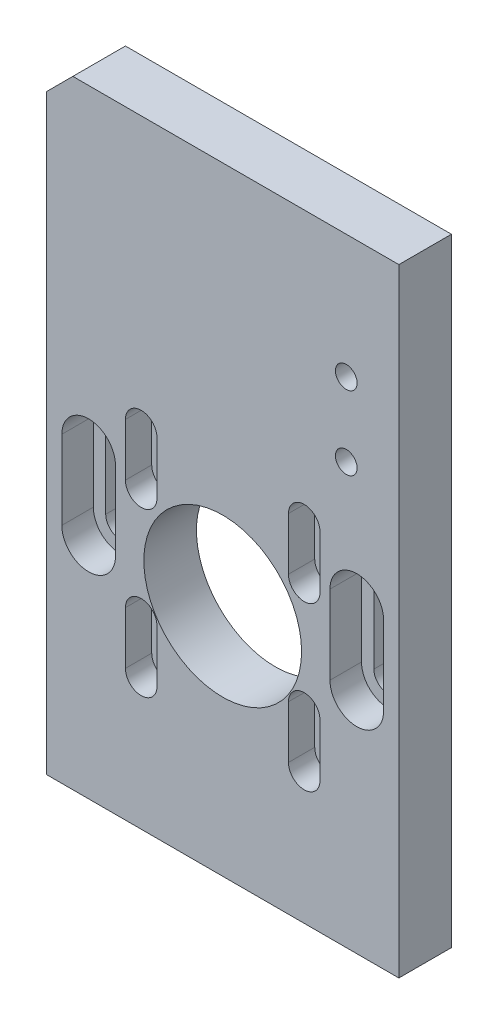
from build123d import *

# Parameters (mm, degrees)
BOSS_EXTRUDE1_DEPTH  = 10
SKETCH2_R            = 15
MOTOR_HOLE_DEPTH     = 11
SCREW_HOLE_DEPTH     = 5
CUT_EXTRUDE3_DEPTH   = 6
LPATTERN1_COUNT      = 2
LPATTERN1_PITCH      = 31
LPATTERN1_COUNT_DIR2 = 2
LPATTERN1_PITCH_DIR2 = 31
CUT_EXTRUDE4_DEPTH   = 6
CUT_EXTRUDE5_DEPTH   = 5
SKETCH8_R            = 2.065
CUT_EXTRUDE6_DEPTH   = 11


with BuildPart() as part:
    # Sketch1 → Boss-Extrude1 (new body)
    with BuildSketch(Plane.XY):
        Polygon((-33.5, 0), (33.5, 0), (33.5, 117.5), (-28.5, 117.5), (-33.5, 112.5), align=None)
    extrude(amount=BOSS_EXTRUDE1_DEPTH)

    # Sketch2 → Motor Hole (cut, through all)
    with BuildSketch(Plane.XY.offset(10)):
        with Locations((0, 44.5)):
            Circle(SKETCH2_R)
    extrude(amount=-MOTOR_HOLE_DEPTH, mode=Mode.SUBTRACT)

    # Sketch3 → Screw Hole (cut)
    with BuildSketch(Plane.XY.offset(10)):
        with BuildLine():
            Line((-12.5, 66), (-12.5, 56))
            ThreePointArc((-12.5, 56), (-15.5, 53), (-18.5, 56))
            Line((-18.5, 56), (-18.5, 66))
            ThreePointArc((-18.5, 66), (-15.5, 69), (-12.5, 66))
        make_face()
    screw_hole = extrude(amount=-SCREW_HOLE_DEPTH, mode=Mode.SUBTRACT)

    # Sketch5 → Cut-Extrude3 (cut, through all)
    with BuildSketch(Plane.XY.offset(5)):
        with BuildLine():
            Line((-17.25, 66), (-17.25, 56))
            ThreePointArc((-17.25, 56), (-15.5, 54.25), (-13.75, 56))
            Line((-13.75, 56), (-13.75, 66))
            ThreePointArc((-13.75, 66), (-15.5, 67.75), (-17.25, 66))
        make_face()
    cut_extrude3 = extrude(amount=-CUT_EXTRUDE3_DEPTH, mode=Mode.SUBTRACT)

    # LPattern1: Screw Hole, Cut-Extrude3 2 × 2
    with Locations(*[(i * LPATTERN1_PITCH, -j * LPATTERN1_PITCH_DIR2, 0) for i in range(LPATTERN1_COUNT) for j in range(LPATTERN1_COUNT_DIR2) if (i, j) != (0, 0)]):
        add(screw_hole, mode=Mode.SUBTRACT)
        add(cut_extrude3, mode=Mode.SUBTRACT)

    # Sketch6 → Cut-Extrude4 (cut)
    with BuildSketch(Plane.XY.offset(10)):
        with BuildLine():
            Line((-20.4, 57.5), (-20.4, 42.5))
            ThreePointArc((-20.4, 42.5), (-25.5, 37.4), (-30.6, 42.5))
            Line((-30.6, 42.5), (-30.6, 57.5))
            ThreePointArc((-30.6, 57.5), (-25.5, 62.6), (-20.4, 57.5))
        make_face()
    cut_extrude4 = extrude(amount=-CUT_EXTRUDE4_DEPTH, mode=Mode.SUBTRACT)

    # Sketch7 → Cut-Extrude5 (cut, through all)
    with BuildSketch(Plane.XY.offset(4)):
        with BuildLine():
            Line((-28.25, 57.5), (-28.25, 42.5))
            ThreePointArc((-28.25, 42.5), (-25.5, 39.75), (-22.75, 42.5))
            Line((-22.75, 42.5), (-22.75, 57.5))
            ThreePointArc((-22.75, 57.5), (-25.5, 60.25), (-28.25, 57.5))
        make_face()
    cut_extrude5 = extrude(amount=-CUT_EXTRUDE5_DEPTH, mode=Mode.SUBTRACT)

    # Mirror1: Cut-Extrude4, Cut-Extrude5 across plane
    add(cut_extrude4.mirror(Plane(origin=(0, 0, 0), x_dir=(0, 0, 1), z_dir=(1, 0, 0))), mode=Mode.SUBTRACT)
    add(cut_extrude5.mirror(Plane(origin=(0, 0, 0), x_dir=(0, 0, 1), z_dir=(1, 0, 0))), mode=Mode.SUBTRACT)

    # Sketch8 → Cut-Extrude6 (cut, through all)
    with BuildSketch(Plane.XY.offset(10)):
        with Locations((23.5, 94)):
            Circle(SKETCH8_R)
        with Locations((23.5, 80)):
            Circle(SKETCH8_R)
    extrude(amount=-CUT_EXTRUDE6_DEPTH, mode=Mode.SUBTRACT)


solid = part.part
